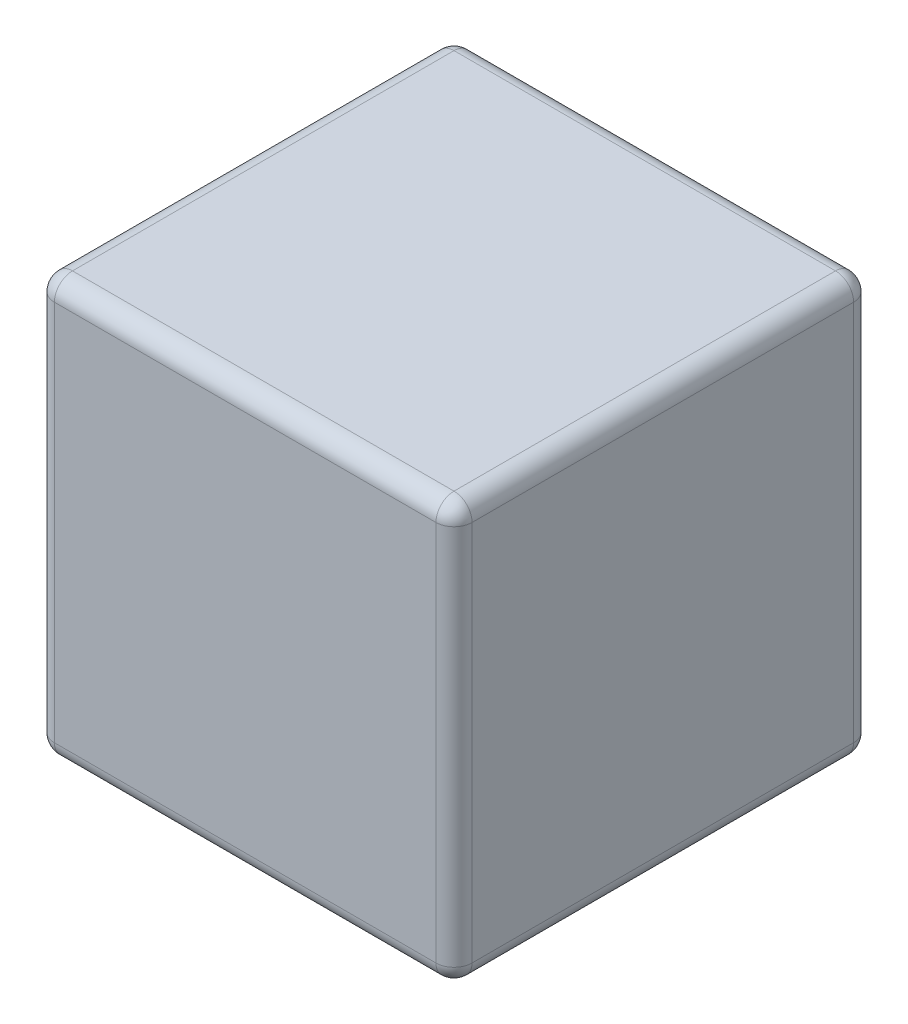
from build123d import *

# Parameters (mm, degrees)
SKETCH1_W           = 11.55
SKETCH1_H           = 11.55
BOSS_EXTRUDE1_DEPTH = 11.55
FILLET1_R           = 0.5


with BuildPart() as part:
    # Sketch1 → Boss-Extrude1 (new body)
    with BuildSketch(Plane.XY):
        Rectangle(SKETCH1_W, SKETCH1_H)
    extrude(amount=BOSS_EXTRUDE1_DEPTH)

    # Fillet1
    fillet1_edges = [part.edges().sort_by_distance(p)[0] for p in [
        (-5.775, 0, 11.55),
        (0, -5.775, 11.55),
        (5.775, 0, 11.55),
        (0, -5.775, 0),
        (-5.775, 0, 0),
        (0, 5.775, 0),
        (5.775, 0, 0),
        (0, 5.775, 11.55),
        (5.775, -5.775, 5.775),
        (-5.775, -5.775, 5.775),
        (-5.775, 5.775, 5.775),
        (5.775, 5.775, 5.775),
    ]]
    fillet(fillet1_edges, radius=FILLET1_R)


solid = part.part
